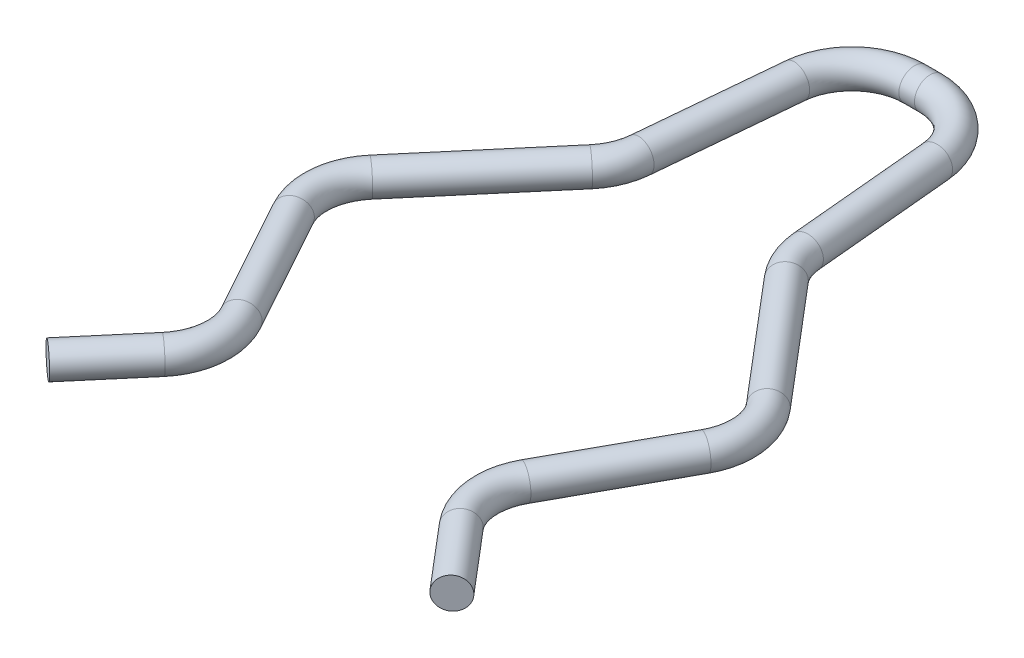
from build123d import *

# Parameters (mm, degrees)
SWEEP2_PROFILE_R = 0.5


with BuildPart() as part:
    # Sweep2: sweep along a path in Sketch1
    with BuildLine(Plane(origin=(0, 0, 0), x_dir=(1, 0, 0), z_dir=(0, 1, 0))) as sweep2_path:
        Line((-6.463671569, -8.451131015), (-4.767321422, -6.453268913))
        ThreePointArc((-4.767321422, -6.453268913), (-4.301937475, -5.359006878), (-4.539997559, -4.193966529))
        Line((-4.539997559, -4.193966529), (-6.586268207, -0.47839801))
        ThreePointArc((-6.586268207, -0.47839801), (-6.824328291, 0.686642339), (-6.358944344, 1.780904374))
        Line((-6.358944344, 1.780904374), (-3.129650798, 5.584177656))
        ThreePointArc((-3.129650798, 5.584177656), (-2.810607738, 6.103358408), (-2.662715036, 6.694513951))
        Line((-2.662715036, 6.694513951), (-2.241504291, 11.249767737))
        ThreePointArc((-2.241504291, 11.249767737), (-1.597535355, 12.543505756), (-0.25, 13.065619269))
        Line((-0.25, 13.065619269), (0.25, 13.065619269))
        ThreePointArc((0.25, 13.065619269), (1.597535355, 12.543505756), (2.241504291, 11.249767737))
        Line((2.241504291, 11.249767737), (2.662715036, 6.694513951))
        ThreePointArc((2.662715036, 6.694513951), (2.810607738, 6.103358408), (3.129650798, 5.584177656))
        Line((3.129650798, 5.584177656), (6.358944344, 1.780904374))
        ThreePointArc((6.358944344, 1.780904374), (6.824328291, 0.686642339), (6.586268207, -0.47839801))
        Line((6.586268207, -0.47839801), (4.539997559, -4.193966529))
        ThreePointArc((4.539997559, -4.193966529), (4.301937475, -5.359006878), (4.767321422, -6.453268913))
        Line((4.767321422, -6.453268913), (6.463671569, -8.451131015))
    # Sweep2 profile (on start of the path) → Sweep2 (sweep)
    with BuildSketch(Plane(origin=(-6.463671569, 0, 8.451131015), x_dir=(-0.762284265, 0, -0.647242381), z_dir=(0.647242381, 0, -0.762284265))):
        Circle(SWEEP2_PROFILE_R)
    sweep(path=sweep2_path.line)


solid = part.part
